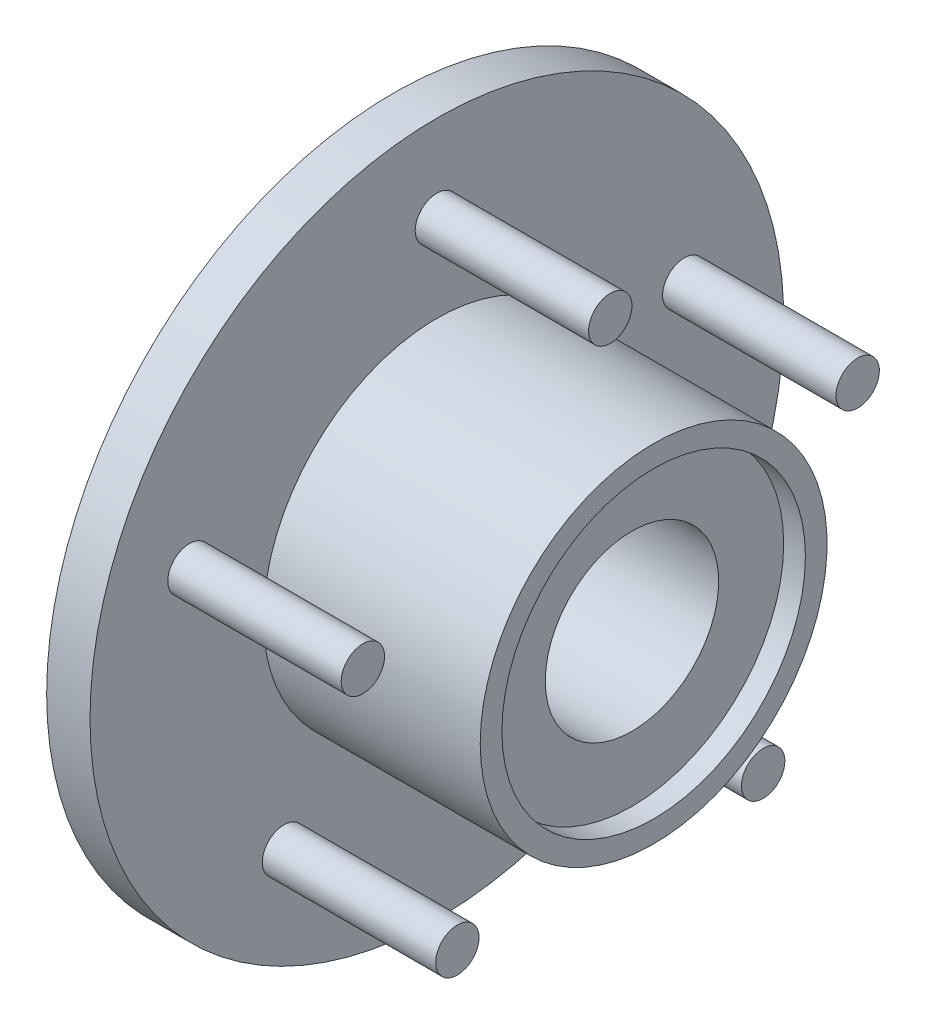
from build123d import *

# Parameters (mm, degrees)
SKETCH3_R           = 3.175
BOSS_EXTRUDE1_DEPTH = 25.4
CIRPATTERN3_COUNT   = 5


with BuildPart() as part:
    # Sketch1 → Revolve1 (revolve)
    with BuildSketch(Plane.XY):
        Polygon((0, 25.4), (12.7, 25.4), (12.7, 50.8), (19.05, 50.8), (19.05, 25.4), (50.8, 25.4), (50.8, 22.225), (47.625, 22.225), (47.625, 12.7), (3.175, 12.7), (3.175, 22.225), (0, 22.225), align=None)
    revolve(axis=Axis((0, 0, 0), (1, 0, 0)))

    # Sketch3 → Boss-Extrude1 (add)
    with BuildSketch(Plane(origin=(19.05, 0, 0), x_dir=(0, 0, -1), z_dir=(1, 0, 0))):
        with Locations((0, 38.1)):
            Circle(SKETCH3_R)
    boss_extrude1 = extrude(amount=BOSS_EXTRUDE1_DEPTH)

    # CirPattern3: Boss-Extrude1 ×5 about axis
    cirpattern3_axis = Axis((53.34, 0, 0), (-1, 0, 0))
    for i in range(1, CIRPATTERN3_COUNT):
        add(boss_extrude1.rotate(cirpattern3_axis, i * 360 / CIRPATTERN3_COUNT))


solid = part.part
